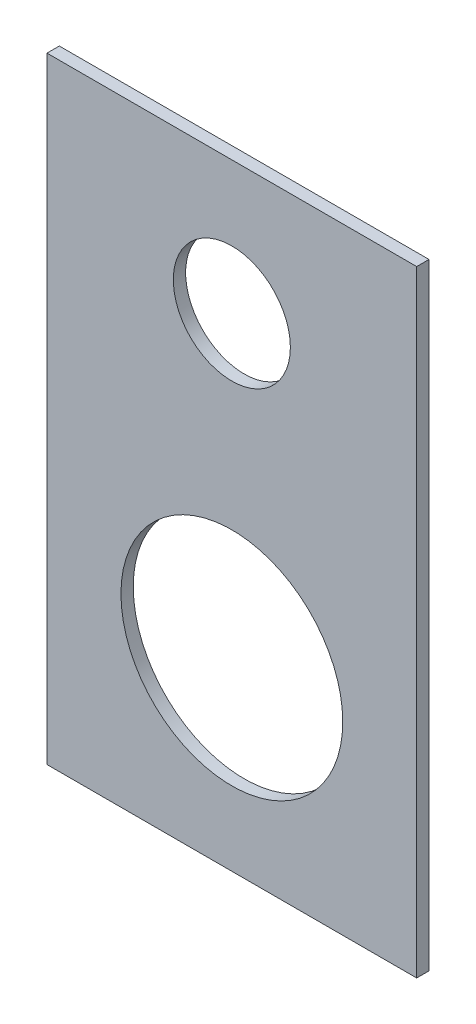
from build123d import *

# Parameters (mm, degrees)
SKETCH1_W      = 300
SKETCH1_H      = 500
SKETCH1_R      = 90
SKETCH1_R_2    = 47.5
EXTRUDE1_DEPTH = 10


with BuildPart() as part:
    # Sketch1 → Extrude1 (new body)
    with BuildSketch(Plane.XY):
        with Locations((150, 250)):
            Rectangle(SKETCH1_W, SKETCH1_H)
        with Locations((150, 150)):
            Circle(SKETCH1_R, mode=Mode.SUBTRACT)
        with Locations((150, 392)):
            Circle(SKETCH1_R_2, mode=Mode.SUBTRACT)
    extrude(amount=-EXTRUDE1_DEPTH)


solid = part.part
